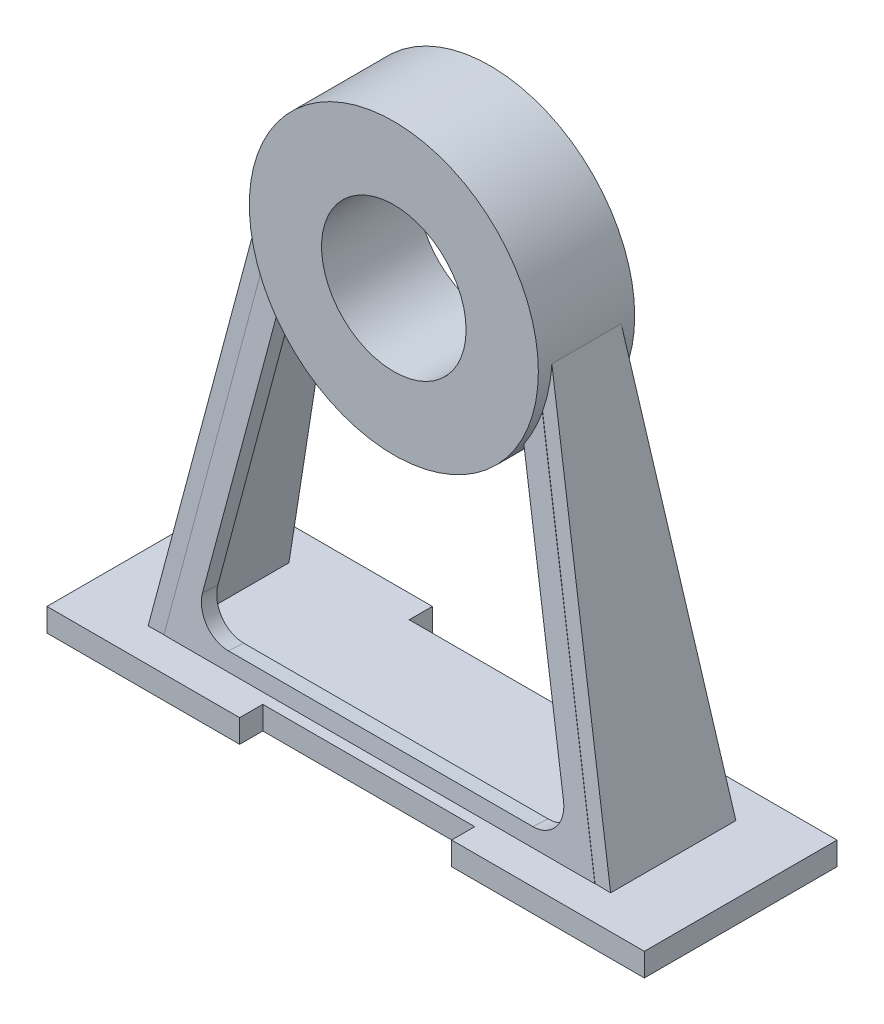
from build123d import *

# Parameters (mm, degrees)
BOSS_EXTRUDE1_DEPTH  = 12
SKETCH2_R            = 75
SKETCH2_R_2          = 37.5
BOSS_EXTRUDE2_DEPTH  = 25
BOSS_EXTRUDE3_DEPTH  = 8
BOSS_EXTRUDE11_DEPTH = 8


with BuildPart() as part:
    # Sketch1 → Boss-Extrude1 (new body)
    with BuildSketch(Plane(origin=(0, 0, 0), x_dir=(1, 0, 0), z_dir=(0, 1, 0))):
        Polygon((0, -50), (0, 50), (100, 50), (100, 38), (210, 38), (210, 50), (310, 50), (310, -50), (210, -50), (210, -38), (100, -38), (100, -50), align=None)
    extrude(amount=BOSS_EXTRUDE1_DEPTH)



with BuildPart() as body_2:
    # Sketch2 → Boss-Extrude2 (new body, symmetric)
    with BuildSketch(Plane.XY):
        with Locations((155, 220)):
            Circle(SKETCH2_R)
        with Locations((155, 220)):
            Circle(SKETCH2_R_2, mode=Mode.SUBTRACT)
    extrude(amount=BOSS_EXTRUDE2_DEPTH, both=True)


with BuildPart() as part_1:
    add(part.part)

    add(body_2.part)  # Boss-Extrude3 merges body 2
    # Sketch6 → Boss-Extrude3 (add)
    with BuildSketch(Plane(origin=(30.95497803, -6.696990439, 0), x_dir=(0, 0, -1), z_dir=(0.977387925, -0.211454118, 0))):
        Polygon((18, 231.941672957), (-18, 231.941672957), (-32.5, 19.129549242), (32.5, 19.129549242), align=None)
    boss_extrude3 = extrude(amount=BOSS_EXTRUDE3_DEPTH)

    # Mirror2: Boss-Extrude3 across plane
    add(boss_extrude3.mirror(Plane(origin=(155, 0, 0), x_dir=(0, 0, 1), z_dir=(1, 0, 0))))


with BuildPart() as body_2_2:
    # Sketch7 → Boss-Extrude11 (new body)
    with BuildSketch(Plane(origin=(0, 2.312702347, 33.175316423), x_dir=(-1, 0, 0), z_dir=(0, -0.069542765, -0.997578971))):
        with BuildLine():
            Line((-83.324181623, 195.701116483), (-43.185081681, 9.719008722))
            Line((-43.185081681, 9.719008722), (-266.814918319, 9.719008722))
            Line((-266.814918319, 9.719008722), (-226.675818377, 195.701116483))
            add(Edge.make_bspline(
                [(-226.675818377, 195.701116483), (-223.708746902, 186.093264091), (-218.304519789, 177.60755028)],
                knots=[0.298843639, 0.298843639, 0.298843639, 0.565986011, 0.565986011, 0.565986011], degree=2, weights=[1, 0.991092624, 1]))
            Line((-218.304519789, 177.60755028), (-248.675921878, 36.883483611))
            ThreePointArc((-248.675921878, 36.883483611), (-245.685430986, 24.297414465), (-234.013517618, 18.719008722))
            Line((-234.013517618, 18.719008722), (-75.986482382, 18.719008722))
            ThreePointArc((-75.986482382, 18.719008722), (-64.314569014, 24.297414465), (-61.324078122, 36.883483611))
            Line((-61.324078122, 36.883483611), (-91.695480211, 177.60755028))
            add(Edge.make_bspline(
                [(-91.695480211, 177.60755028), (-86.291253098, 186.093264091), (-83.324181623, 195.701116483)],
                knots=[5.717199296, 5.717199296, 5.717199296, 5.984341668, 5.984341668, 5.984341668], degree=2, weights=[1, 0.991092624, 1]))
        make_face()
    extrude(amount=BOSS_EXTRUDE11_DEPTH)


solid = Compound([part_1.part, body_2_2.part])
